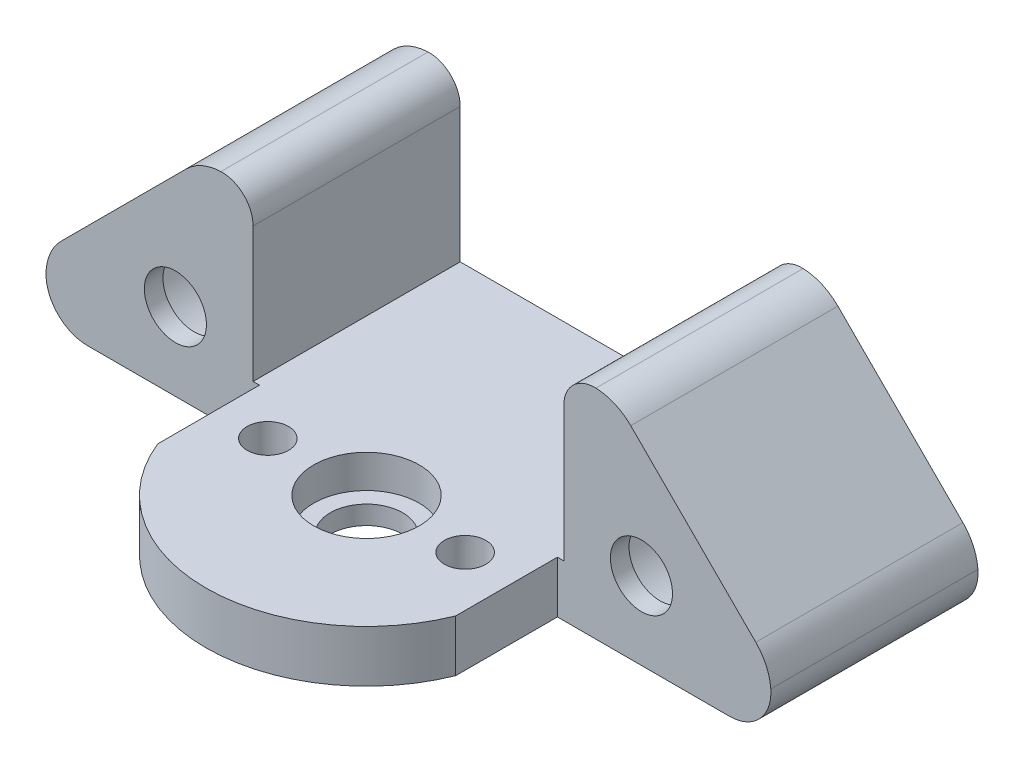
from build123d import *

# Parameters (mm, degrees)
ESQUISSE1_R             = 3.5
BOSS_EXTRU_1_DEPTH      = 5
ESQUISSE2_R             = 5.1
ENL_V_MAT_EXTRU_1_DEPTH = 3.2
ESQUISSE3_R             = 2
ENL_V_MAT_EXTRU_2_DEPTH = 5
ESQUISSE4_R             = 3
BOSS_EXTRU_2_DEPTH      = 20
ESQUISSE5_R             = 6.1
ENL_V_MAT_EXTRU_3_DEPTH = 18.2
ENL_V_MAT_EXTRU_4_DEPTH = 1
CONG_1_R                = 5
CONG_2_R                = 3
CONG_3_R                = 4


with BuildPart() as part:
    # Esquisse1 → Boss.-Extru.1 (new body)
    with BuildSketch(Plane(origin=(0, 0, 0), x_dir=(1, 0, 0), z_dir=(0, 1, 0))):
        with BuildLine():
            Line((-14.385, -5.772501624), (-14.385, 24.05))
            Line((-14.385, 24.05), (14.385, 24.05))
            Line((14.385, 24.05), (14.385, -5.772501624))
            ThreePointArc((14.385, -5.772501624), (0, -15.5), (-14.385, -5.772501624))
        make_face()
        Circle(ESQUISSE1_R, mode=Mode.SUBTRACT)
    extrude(amount=BOSS_EXTRU_1_DEPTH)

    # Esquisse2 → Enlèv. mat.-Extru.1 (cut)
    with BuildSketch(Plane(origin=(0, 5, 0), x_dir=(1, 0, 0), z_dir=(0, 1, 0))):
        Circle(ESQUISSE2_R)
    extrude(amount=-ENL_V_MAT_EXTRU_1_DEPTH, mode=Mode.SUBTRACT)

    # Esquisse3 → Enlèv. mat.-Extru.2 (cut)
    with BuildSketch(Plane(origin=(0, 5, 0), x_dir=(1, 0, 0), z_dir=(0, 1, 0))):
        with Locations((-9.525, 0)):
            Circle(ESQUISSE3_R)
        with Locations((9.525, 0)):
            Circle(ESQUISSE3_R)
    extrude(amount=-ENL_V_MAT_EXTRU_2_DEPTH, mode=Mode.SUBTRACT)

    # Esquisse4 → Boss.-Extru.2 (add)
    with BuildSketch(Plane(origin=(0, 0, -24.05), x_dir=(-1, 0, 0), z_dir=(0, 0, -1))):
        Polygon((-14.385, 0), (-14.385, 5), (-15, 5), (-15, 21), (-20, 21), (-35, 6), (-35, 0), align=None)
        with Locations((-22.5, 7.5)):
            Circle(ESQUISSE4_R, mode=Mode.SUBTRACT)
        Polygon((14.385, 0), (14.385, 5), (15, 5), (15, 21), (20, 21), (35, 6), (35, 0), align=None)
        with Locations((22.5, 7.5)):
            Circle(ESQUISSE4_R, mode=Mode.SUBTRACT)
    extrude(amount=-BOSS_EXTRU_2_DEPTH)

    # Esquisse5 → Enlèv. mat.-Extru.3 (cut)
    with BuildSketch(Plane(origin=(0, 0, -24.05), x_dir=(-1, 0, 0), z_dir=(0, 0, -1))):
        with Locations((22.5, 7.5)):
            Circle(ESQUISSE5_R)
        with Locations((-22.5, 7.5)):
            Circle(ESQUISSE5_R)
    extrude(amount=-ENL_V_MAT_EXTRU_3_DEPTH, mode=Mode.SUBTRACT)

    # Esquisse6 → Enlèv. mat.-Extru.4 (cut)
    with BuildSketch(Plane.XZ):
        with BuildLine():
            Line((8.342363502, -19.358969855), (8.343533076, -18.329609262))
            ThreePointArc((8.343533076, -18.329609262), (8.343961139, -17.756571127), (8.344002975, -17.183532834))
            ThreePointArc((8.344002975, -17.183532834), (8.343684943, -16.50722845), (8.343088323, -15.830924255))
            Line((8.343088323, -15.830924255), (8.339257329, -12.310243069))
            Line((8.339257329, -12.310243069), (8.309606623, -12.223565569))
            ThreePointArc((8.309606623, -12.223565569), (8.271088436, -12.12918973), (8.221924224, -12.039896226))
            ThreePointArc((8.221924224, -12.039896226), (8.162679033, -11.956686695), (8.094271322, -11.880830225))
            ThreePointArc((8.094271322, -11.880830225), (8.018047353, -11.81377124), (7.934583004, -11.75597242))
            ThreePointArc((7.934583004, -11.75597242), (7.846049527, -11.709031345), (7.752516957, -11.673068874))
            Line((7.752516957, -11.673068874), (7.659172329, -11.643493069))
            Line((7.659172329, -11.643493069), (4.111024665, -11.643493069))
            Line((4.111024665, -11.643493069), (0.562877016, -11.643493069))
            Line((0.562877016, -11.643493069), (0.515098951, -11.67993489))
            ThreePointArc((0.515098951, -11.67993489), (0.48314839, -11.711557417), (0.460295821, -11.750268947))
            ThreePointArc((0.460295821, -11.750268947), (0.443436061, -11.8003562), (0.434765644, -11.852488803))
            ThreePointArc((0.434765644, -11.852488803), (0.428453619, -11.951581938), (0.426357246, -12.050853769))
            ThreePointArc((0.426357246, -12.050853769), (0.426744227, -12.378423047), (0.427817135, -12.705990798))
            ThreePointArc((0.427817135, -12.705990798), (0.429184117, -12.993170793), (0.430803242, -13.280349477))
            ThreePointArc((0.430803242, -13.280349477), (0.43207785, -13.376723895), (0.434730026, -13.473070244))
            ThreePointArc((0.434730026, -13.473070244), (0.437417166, -13.523869636), (0.441949088, -13.574537779))
            ThreePointArc((0.441949088, -13.574537779), (0.447729199, -13.598158467), (0.459498455, -13.619438298))
            ThreePointArc((0.459498455, -13.619438298), (0.466181454, -13.627929545), (0.473345252, -13.636019277))
            ThreePointArc((0.473345252, -13.636019277), (0.482600142, -13.645574505), (0.492149949, -13.654834988))
            ThreePointArc((0.492149949, -13.654834988), (0.502216695, -13.664004337), (0.512563954, -13.672855921))
            ThreePointArc((0.512563954, -13.672855921), (0.521853547, -13.680192381), (0.5314793, -13.68708187))
            Line((0.5314793, -13.68708187), (0.575563868, -13.717085569))
            Line((0.575563868, -13.717085569), (3.331111295, -13.717085569))
            Line((3.331111295, -13.717085569), (6.086658722, -13.717085569))
            Line((6.086658722, -13.717085569), (6.146158025, -13.747089319))
            ThreePointArc((6.146158025, -13.747089319), (6.161202408, -13.755300174), (6.175681022, -13.764471944))
            ThreePointArc((6.175681022, -13.764471944), (6.187789518, -13.773567521), (6.198989828, -13.783760569))
            ThreePointArc((6.198989828, -13.783760569), (6.209182876, -13.794960879), (6.218278452, -13.807069375))
            ThreePointArc((6.218278452, -13.807069375), (6.227450174, -13.821547906), (6.235660992, -13.836592201))
            Line((6.235660992, -13.836592201), (6.265664828, -13.896091675))
            Line((6.265664828, -13.896091675), (6.265664828, -16.651639102))
            Line((6.265664828, -16.651639102), (6.265664828, -19.407186529))
            Line((6.265664828, -19.407186529), (6.295668578, -19.451271172))
            ThreePointArc((6.295668578, -19.451271172), (6.302558088, -19.46089691), (6.309894623, -19.470186443))
            ThreePointArc((6.309894623, -19.470186443), (6.31874643, -19.480533715), (6.327916022, -19.490600448))
            ThreePointArc((6.327916022, -19.490600448), (6.337176813, -19.500150272), (6.346732387, -19.509405131))
            ThreePointArc((6.346732387, -19.509405131), (6.354822505, -19.516568964), (6.363314166, -19.523251942))
            ThreePointArc((6.363314166, -19.523251942), (6.384683145, -19.535053583), (6.408405069, -19.54081399))
            ThreePointArc((6.408405069, -19.54081399), (6.459663134, -19.545289655), (6.511048751, -19.547923892))
            ThreePointArc((6.511048751, -19.547923892), (6.608580973, -19.550481886), (6.706139587, -19.551662733))
            ThreePointArc((6.706139587, -19.551662733), (6.998117602, -19.553010218), (7.290096666, -19.554107185))
            ThreePointArc((7.290096666, -19.554107185), (7.524254391, -19.554710419), (7.758412758, -19.554961479))
            ThreePointArc((7.758412758, -19.554961479), (7.885326499, -19.554483494), (8.012232095, -19.552968403))
            ThreePointArc((8.012232095, -19.552968403), (8.094243111, -19.551341013), (8.176239314, -19.549087608))
            ThreePointArc((8.176239314, -19.549087608), (8.19854534, -19.546241067), (8.219903438, -19.539205923))
            ThreePointArc((8.219903438, -19.539205923), (8.240352778, -19.528468606), (8.259112671, -19.51499523))
            ThreePointArc((8.259112671, -19.51499523), (8.278505712, -19.497285611), (8.296129431, -19.477814476))
            ThreePointArc((8.296129431, -19.477814476), (8.311541507, -19.457114417), (8.324894626, -19.435030062))
            ThreePointArc((8.324894626, -19.435030062), (8.333693067, -19.415121249), (8.339223697, -19.394069276))
            ThreePointArc((8.339223697, -19.394069276), (8.341566997, -19.37658875), (8.342363502, -19.358969855))
        make_face()
        with BuildLine():
            Line((-0.491991588, -11.67993494), (-0.539762077, -11.643493069))
            Line((-0.539762077, -11.643493069), (-1.420917381, -11.639757415))
            ThreePointArc((-1.420917381, -11.639757415), (-1.747214244, -11.638711869), (-2.073512572, -11.638341758))
            ThreePointArc((-2.073512572, -11.638341758), (-2.175033504, -11.640348396), (-2.276394662, -11.646385083))
            ThreePointArc((-2.276394662, -11.646385083), (-2.328884144, -11.654455854), (-2.379634286, -11.670098941))
            ThreePointArc((-2.379634286, -11.670098941), (-2.416169854, -11.690870666), (-2.445255382, -11.721207844))
            Line((-2.445255382, -11.721207844), (-2.475427672, -11.763508069))
            Line((-2.475427672, -11.763508069), (-2.482095172, -13.083673069))
            Line((-2.482095172, -13.083673069), (-2.488762672, -14.403838069))
            Line((-2.488762672, -14.403838069), (-2.519269271, -14.452898174))
            ThreePointArc((-2.519269271, -14.452898174), (-2.526907006, -14.464060642), (-2.535491139, -14.474512835))
            ThreePointArc((-2.535491139, -14.474512835), (-2.546055591, -14.485592902), (-2.557270541, -14.496014056))
            ThreePointArc((-2.557270541, -14.496014056), (-2.569349469, -14.505956874), (-2.581998845, -14.515163036))
            ThreePointArc((-2.581998845, -14.515163036), (-2.594294734, -14.522910141), (-2.607131493, -14.529723669))
            ThreePointArc((-2.607131493, -14.529723669), (-2.641745445, -14.54234604), (-2.678189787, -14.547755283))
            ThreePointArc((-2.678189787, -14.547755283), (-2.775374275, -14.551455498), (-2.872606073, -14.553575303))
            ThreePointArc((-2.872606073, -14.553575303), (-3.055579463, -14.555395903), (-3.238561332, -14.555855882))
            ThreePointArc((-3.238561332, -14.555855882), (-3.811398944, -14.55504775), (-4.384236176, -14.554004608))
            Line((-4.384236176, -14.554004608), (-6.102547672, -14.550523069))
            Line((-6.102547672, -14.550523069), (-6.147440323, -14.518504814))
            ThreePointArc((-6.147440323, -14.518504814), (-6.157291607, -14.510812588), (-6.166438911, -14.502295254))
            ThreePointArc((-6.166438911, -14.502295254), (-6.176719833, -14.491316244), (-6.186437583, -14.479835767))
            ThreePointArc((-6.186437583, -14.479835767), (-6.195718842, -14.467689001), (-6.204383813, -14.455095195))
            ThreePointArc((-6.204383813, -14.455095195), (-6.211210705, -14.443703164), (-6.217156209, -14.431827314))
            ThreePointArc((-6.217156209, -14.431827314), (-6.227887323, -14.400748673), (-6.232632397, -14.368213723))
            ThreePointArc((-6.232632397, -14.368213723), (-6.236236399, -14.284260772), (-6.238480315, -14.200260465))
            ThreePointArc((-6.238480315, -14.200260465), (-6.240663145, -14.048106528), (-6.241548351, -13.895939509))
            ThreePointArc((-6.241548351, -13.895939509), (-6.242045287, -13.48924374), (-6.242272255, -13.082547731))
            Line((-6.242272255, -13.082547731), (-6.242565172, -11.787454608))
            Line((-6.242565172, -11.787454608), (-6.272568922, -11.743369965))
            ThreePointArc((-6.272568922, -11.743369965), (-6.279458607, -11.733744157), (-6.286795487, -11.724454694))
            ThreePointArc((-6.286795487, -11.724454694), (-6.295648049, -11.714107365), (-6.304818499, -11.704040689))
            ThreePointArc((-6.304818499, -11.704040689), (-6.31408042, -11.694490822), (-6.323637198, -11.685236032))
            ThreePointArc((-6.323637198, -11.685236032), (-6.331728681, -11.678072104), (-6.340221777, -11.671389195))
            ThreePointArc((-6.340221777, -11.671389195), (-6.361690609, -11.65956112), (-6.38552652, -11.653845923))
            ThreePointArc((-6.38552652, -11.653845923), (-6.437207837, -11.649530575), (-6.48901052, -11.647068315))
            ThreePointArc((-6.48901052, -11.647068315), (-6.587579598, -11.64483958), (-6.686170189, -11.64398761))
            ThreePointArc((-6.686170189, -11.64398761), (-6.984432578, -11.643616561), (-7.282695172, -11.643493069))
            ThreePointArc((-7.282695172, -11.643493069), (-7.579282666, -11.64361807), (-7.875869949, -11.643992798))
            ThreePointArc((-7.875869949, -11.643992798), (-7.975340332, -11.644844411), (-8.074789598, -11.647063795))
            ThreePointArc((-8.074789598, -11.647063795), (-8.127298753, -11.649491806), (-8.179694869, -11.653705305))
            ThreePointArc((-8.179694869, -11.653705305), (-8.203202336, -11.659290761), (-8.22434461, -11.670987025))
            ThreePointArc((-8.22434461, -11.670987025), (-8.232542, -11.677400426), (-8.240441608, -11.684177233))
            ThreePointArc((-8.240441608, -11.684177233), (-8.249549767, -11.692578742), (-8.258428723, -11.701222124))
            ThreePointArc((-8.258428723, -11.701222124), (-8.267072059, -11.71010114), (-8.27547352, -11.719209359))
            ThreePointArc((-8.27547352, -11.719209359), (-8.28225033, -11.727109049), (-8.288663729, -11.735306522))
            Line((-8.288663729, -11.735306522), (-8.316157672, -11.772132053))
            Line((-8.316157672, -11.772132053), (-8.316157672, -15.321597561))
            Line((-8.316157672, -15.321597561), (-8.316157672, -18.871063069))
            Line((-8.316157672, -18.871063069), (-8.286581749, -18.964408069))
            ThreePointArc((-8.286581749, -18.964408069), (-8.250572256, -19.058162828), (-8.203621326, -19.146944856))
            ThreePointArc((-8.203621326, -19.146944856), (-8.146016595, -19.230319866), (-8.079106244, -19.306429669))
            ThreePointArc((-8.079106244, -19.306429669), (-8.003360643, -19.37468957), (-7.920236881, -19.433742515))
            ThreePointArc((-7.920236881, -19.433742515), (-7.830689229, -19.482924565), (-7.736085786, -19.521497153))
            Line((-7.736085786, -19.521497153), (-7.649407672, -19.551148069))
            Line((-7.649407672, -19.551148069), (-4.395667672, -19.553502336))
            ThreePointArc((-4.395667672, -19.553502336), (-3.518256313, -19.553972304), (-2.64084484, -19.554114119))
            ThreePointArc((-2.64084484, -19.554114119), (-2.191770321, -19.553576545), (-1.742698292, -19.55198724))
            ThreePointArc((-1.742698292, -19.55198724), (-1.448402055, -19.550395209), (-1.154108331, -19.548391753))
            ThreePointArc((-1.154108331, -19.548391753), (-1.106356976, -19.54555384), (-1.05915598, -19.537787785))
            ThreePointArc((-1.05915598, -19.537787785), (-0.994780641, -19.520480023), (-0.932347651, -19.497116275))
            ThreePointArc((-0.932347651, -19.497116275), (-0.867755015, -19.466356136), (-0.805729426, -19.430701948))
            ThreePointArc((-0.805729426, -19.430701948), (-0.745819784, -19.389846297), (-0.689200741, -19.344540299))
            ThreePointArc((-0.689200741, -19.344540299), (-0.638663657, -19.296852127), (-0.592448249, -19.2449648))
            ThreePointArc((-0.592448249, -19.2449648), (-0.568900157, -19.214361455), (-0.547129438, -19.182469243))
            ThreePointArc((-0.547129438, -19.182469243), (-0.524750912, -19.145943412), (-0.503914823, -19.108516253))
            ThreePointArc((-0.503914823, -19.108516253), (-0.48372861, -19.068485676), (-0.465164914, -19.02767735))
            ThreePointArc((-0.465164914, -19.02767735), (-0.448354309, -18.986366857), (-0.433241284, -18.944405569))
            ThreePointArc((-0.433241284, -18.944405569), (-0.421253513, -18.897024589), (-0.416725246, -18.848360858))
            ThreePointArc((-0.416725246, -18.848360858), (-0.413657376, -18.619994009), (-0.411430371, -18.391617412))
            ThreePointArc((-0.411430371, -18.391617412), (-0.408907048, -17.991553007), (-0.407666341, -17.591482568))
            ThreePointArc((-0.407666341, -17.591482568), (-0.4061133, -16.471052979), (-0.404813477, -15.350623069))
            ThreePointArc((-0.404813477, -15.350623069), (-0.403610373, -14.007424902), (-0.402815601, -12.664226431))
            ThreePointArc((-0.402815601, -12.664226431), (-0.404474356, -12.368394164), (-0.409710063, -12.072603581))
            ThreePointArc((-0.409710063, -12.072603581), (-0.416477475, -11.93029155), (-0.430000639, -11.788461947))
            ThreePointArc((-0.430000639, -11.788461947), (-0.449992296, -11.72791303), (-0.491991588, -11.67993494))
        make_face()
        with BuildLine():
            Line((-6.147440387, -16.676136369), (-6.102547672, -16.644118069))
            Line((-6.102547672, -16.644118069), (-4.383517393, -16.640635073))
            ThreePointArc((-4.383517393, -16.640635073), (-3.811039552, -16.639592806), (-3.238561332, -16.638785255))
            ThreePointArc((-3.238561332, -16.638785255), (-3.055579463, -16.639245234), (-2.872606073, -16.641065834))
            ThreePointArc((-2.872606073, -16.641065834), (-2.775374275, -16.643185639), (-2.678189787, -16.646885854))
            ThreePointArc((-2.678189787, -16.646885854), (-2.641745445, -16.652295098), (-2.607131493, -16.664917468))
            ThreePointArc((-2.607131493, -16.664917468), (-2.594294734, -16.671730996), (-2.581998845, -16.679478101))
            ThreePointArc((-2.581998845, -16.679478101), (-2.569349469, -16.688684263), (-2.557270541, -16.698627081))
            ThreePointArc((-2.557270541, -16.698627081), (-2.546055591, -16.709048235), (-2.535491139, -16.720128302))
            ThreePointArc((-2.535491139, -16.720128302), (-2.526907006, -16.730580496), (-2.519269271, -16.741742963))
            ThreePointArc((-2.519269271, -16.741742963), (-2.509409773, -16.760001097), (-2.501852161, -16.779325994))
            ThreePointArc((-2.501852161, -16.779325994), (-2.496330524, -16.800268093), (-2.493090999, -16.821682235))
            ThreePointArc((-2.493090999, -16.821682235), (-2.490527451, -16.856088157), (-2.489475788, -16.890573418))
            ThreePointArc((-2.489475788, -16.890573418), (-2.488940949, -16.974037482), (-2.488762672, -17.057503069))
            ThreePointArc((-2.488762672, -17.057503069), (-2.488941277, -17.140802492), (-2.489477068, -17.224100384))
            ThreePointArc((-2.489477068, -17.224100384), (-2.490527839, -17.258661879), (-2.493085225, -17.29314464))
            ThreePointArc((-2.493085225, -17.29314464), (-2.496308591, -17.31458212), (-2.501798688, -17.335553874))
            ThreePointArc((-2.501798688, -17.335553874), (-2.509289173, -17.354799865), (-2.519092449, -17.372977085))
            ThreePointArc((-2.519092449, -17.372977085), (-2.52656995, -17.383890623), (-2.534985222, -17.394098538))
            ThreePointArc((-2.534985222, -17.394098538), (-2.545621797, -17.405244741), (-2.556869824, -17.41577358))
            ThreePointArc((-2.556869824, -17.41577358), (-2.568914147, -17.425842106), (-2.581501196, -17.435223318))
            ThreePointArc((-2.581501196, -17.435223318), (-2.593359742, -17.442897302), (-2.605769949, -17.449642813))
            ThreePointArc((-2.605769949, -17.449642813), (-2.639832765, -17.462342811), (-2.675770472, -17.467824286))
            ThreePointArc((-2.675770472, -17.467824286), (-2.772059703, -17.471718551), (-2.86839976, -17.474036915))
            ThreePointArc((-2.86839976, -17.474036915), (-3.049605247, -17.476233052), (-3.230822124, -17.477066481))
            ThreePointArc((-3.230822124, -17.477066481), (-3.797217588, -17.477423657), (-4.363613151, -17.477545052))
            Line((-4.363613151, -17.477545052), (-6.063559065, -17.477555569))
            Line((-6.063559065, -17.477555569), (-6.123058539, -17.447551733))
            ThreePointArc((-6.123058539, -17.447551733), (-6.138102834, -17.439340915), (-6.152581365, -17.430169193))
            ThreePointArc((-6.152581365, -17.430169193), (-6.164689861, -17.421073617), (-6.175890172, -17.410880569))
            ThreePointArc((-6.175890172, -17.410880569), (-6.18608322, -17.399680258), (-6.195178796, -17.387571762))
            ThreePointArc((-6.195178796, -17.387571762), (-6.204350566, -17.373093149), (-6.212561422, -17.358048766))
            ThreePointArc((-6.212561422, -17.358048766), (-6.221909665, -17.337196424), (-6.229319383, -17.315579164))
            ThreePointArc((-6.229319383, -17.315579164), (-6.234676184, -17.293510596), (-6.237961516, -17.271040091))
            ThreePointArc((-6.237961516, -17.271040091), (-6.240543572, -17.237368881), (-6.241630708, -17.203616317))
            ThreePointArc((-6.241630708, -17.203616317), (-6.242156229, -17.130814693), (-6.242272309, -17.058011265))
            ThreePointArc((-6.242272309, -17.058011265), (-6.241340536, -16.969578922), (-6.238761043, -16.881179298))
            ThreePointArc((-6.238761043, -16.881179298), (-6.234488298, -16.833684253), (-6.225380211, -16.786875298))
            ThreePointArc((-6.225380211, -16.786875298), (-6.21419533, -16.755033899), (-6.197233453, -16.725857351))
            ThreePointArc((-6.197233453, -16.725857351), (-6.174394222, -16.698936575), (-6.147440387, -16.676136369))
        make_face(mode=Mode.SUBTRACT)
    extrude(amount=-ENL_V_MAT_EXTRU_4_DEPTH, mode=Mode.SUBTRACT)

    # Congé1
    cong_1_edges = [part.edges().sort_by_distance(p)[0] for p in [
        (20, 21, -14.05),
        (35, 6, -14.05),
        (-20, 21, -14.05),
        (-35, 6, -14.05),
    ]]
    fillet(cong_1_edges, radius=CONG_1_R)

    # Congé2
    cong_2_edges = [part.edges().sort_by_distance(p)[0] for p in [
        (-15, 21, -14.05),
        (15, 21, -14.05),
    ]]
    fillet(cong_2_edges, radius=CONG_2_R)

    # Congé3
    cong_3_edges = [part.edges().sort_by_distance(p)[0] for p in [
        (-35, 0, -14.05),
        (35, 0, -14.05),
    ]]
    fillet(cong_3_edges, radius=CONG_3_R)


solid = part.part
